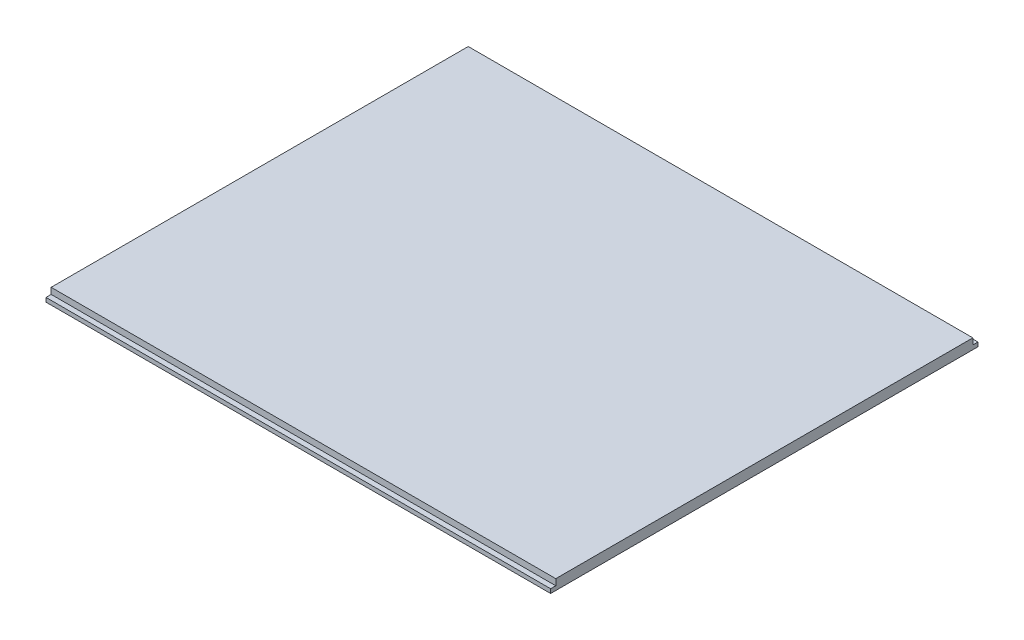
from build123d import *

# Parameters (mm, degrees)
SKETCH2_W           = 98
SKETCH2_H           = 83
BOSS_EXTRUDE1_DEPTH = 2
SKETCH3_W           = 98
SKETCH3_H           = 1
CUT_EXTRUDE1_DEPTH  = 1.2


with BuildPart() as part:
    # Sketch2 → Boss-Extrude1 (new body)
    with BuildSketch(Plane(origin=(0, 0, 0), x_dir=(1, 0, 0), z_dir=(0, 1, 0))):
        with Locations((49, 41.5)):
            Rectangle(SKETCH2_W, SKETCH2_H)
    extrude(amount=BOSS_EXTRUDE1_DEPTH)

    # Sketch3 → Cut-Extrude1 (cut)
    with BuildSketch(Plane(origin=(0, 2, 0), x_dir=(1, 0, 0), z_dir=(0, 1, 0))):
        with Locations((49, 0.5)):
            Rectangle(SKETCH3_W, SKETCH3_H)
        with Locations((49, 82.5)):
            Rectangle(SKETCH3_W, SKETCH3_H)
    extrude(amount=-CUT_EXTRUDE1_DEPTH, mode=Mode.SUBTRACT)


solid = part.part
